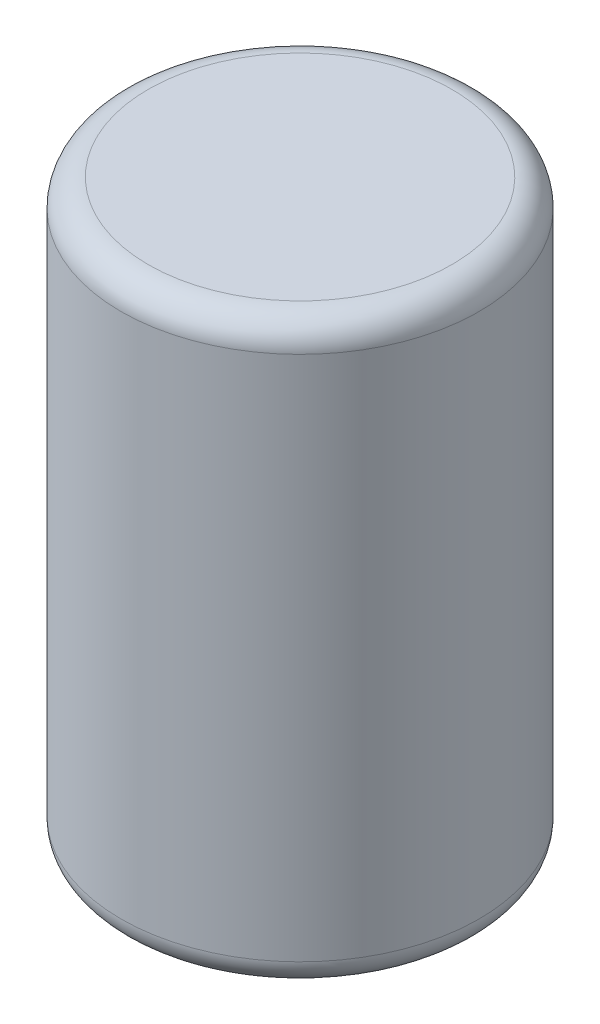
from build123d import *

# Parameters (mm, degrees)
SKETCH1_R           = 6.6
BOSS_EXTRUDE1_DEPTH = 21.4
FILLET1_R           = 1
SKETCH2_R           = 0.3
BOSS_EXTRUDE2_DEPTH = 2


with BuildPart() as part:
    # Sketch1 → Boss-Extrude1 (new body)
    with BuildSketch(Plane(origin=(0, 0, 0), x_dir=(1, 0, 0), z_dir=(0, 1, 0))):
        Circle(SKETCH1_R)
    extrude(amount=BOSS_EXTRUDE1_DEPTH)

    # Fillet1
    fillet1_edges = [part.edges().sort_by_distance(p)[0] for p in [
        (-6.6, 0, 0),
        (-6.6, 21.4, 0),
    ]]
    fillet(fillet1_edges, radius=FILLET1_R)

    # Sketch2 → Boss-Extrude2 (add)
    with BuildSketch(Plane.XZ):
        with Locations((-2.5, 0)):
            Circle(SKETCH2_R)
        with Locations((2.5, 0)):
            Circle(SKETCH2_R)
    extrude(amount=BOSS_EXTRUDE2_DEPTH)


solid = part.part
